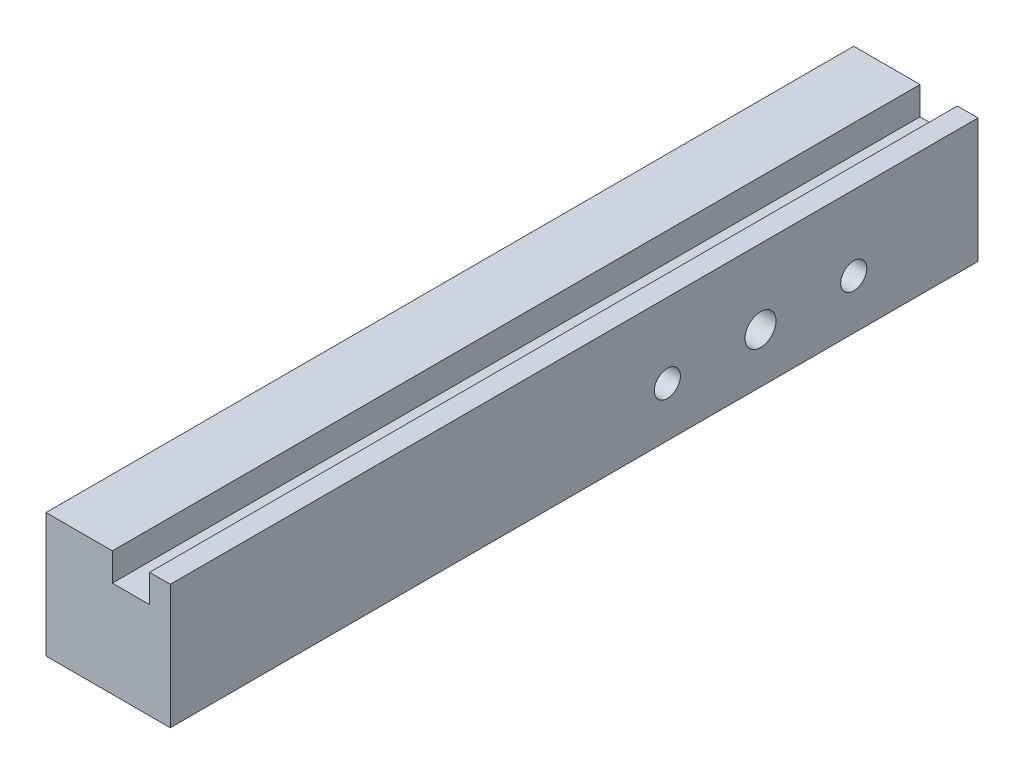
from build123d import *

# Parameters (mm, degrees)
SKETCH_1_W          = 20
SKETCH_1_H          = 20
EXTRUDE_1_DEPTH     = 130
SKETCH_2_W          = 5.996199515
SKETCH_2_H          = 130
CUT_EXTRUDE_1_DEPTH = 4.5
HOLE_WIZARD_M5_1_D  = 4.2
SKETCH_5_R          = 2.5
CUT_EXTRUDE_2_DEPTH = 21


with BuildPart() as part:
    # 草图1 → 凸台-拉伸1 (new body)
    with BuildSketch(Plane.XY):
        with Locations((10, 10)):
            Rectangle(SKETCH_1_W, SKETCH_1_H)
    extrude(amount=EXTRUDE_1_DEPTH)

    # 草图2 → 切除-拉伸1 (cut)
    with BuildSketch(Plane(origin=(0, 20, 0), x_dir=(1, 0, 0), z_dir=(0, 1, 0))):
        with Locations((13.673460813, -65)):
            Rectangle(SKETCH_2_W, SKETCH_2_H)
    extrude(amount=-CUT_EXTRUDE_1_DEPTH, mode=Mode.SUBTRACT)

    # M5 螺纹孔1 (through all)
    with Locations(Plane.ZY):
        with Locations((20, 8), (50, 8)):
            Hole(HOLE_WIZARD_M5_1_D / 2)

    # 草图5 → 切除-拉伸2 (cut, through all)
    with BuildSketch(Plane(origin=(20, 0, 0), x_dir=(0, 0, -1), z_dir=(1, 0, 0))):
        with Locations((-35, 8)):
            Circle(SKETCH_5_R)
    extrude(amount=-CUT_EXTRUDE_2_DEPTH, mode=Mode.SUBTRACT)


solid = part.part
